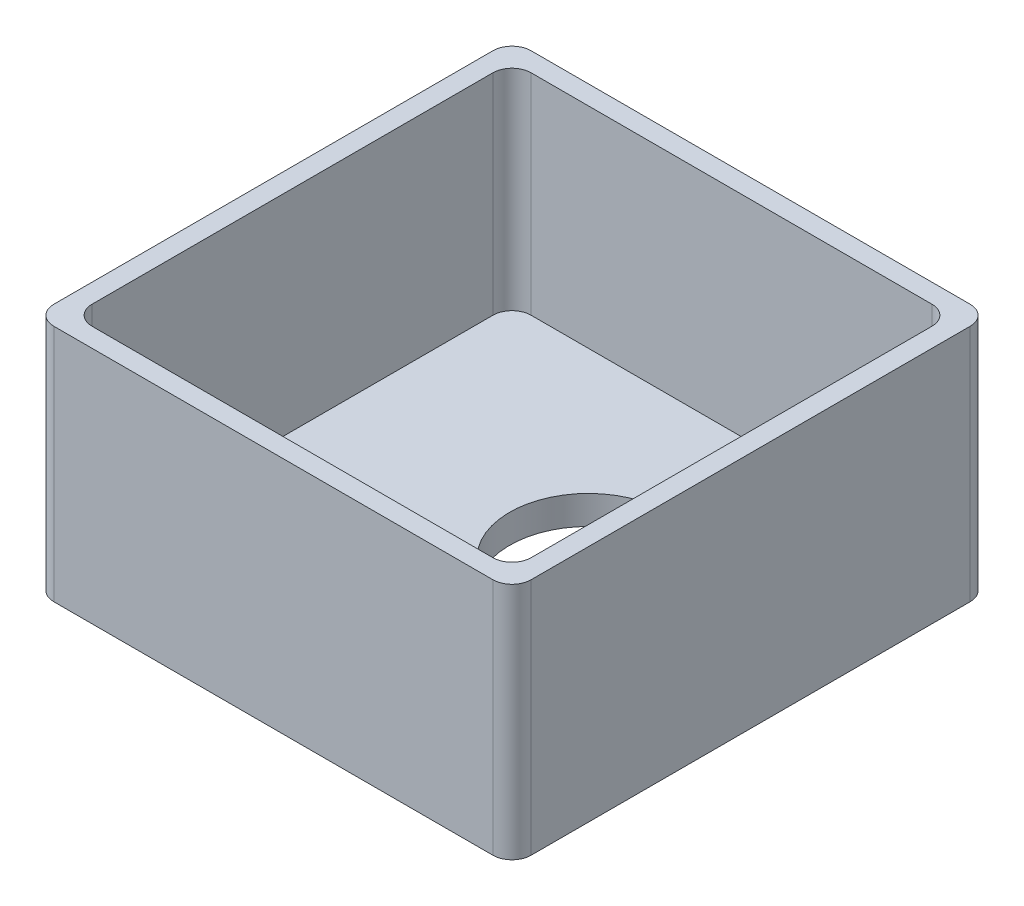
from build123d import *

# Parameters (mm, degrees)
SZKIC3_W                    = 50
SZKIC3_H                    = 50
SZKIC3_R                    = 18
SZKIC3_R_2                  = 8.25
DODANIE_WYCI_GNI_CIE2_DEPTH = 3
SZKIC4_W                    = 50
SZKIC4_H                    = 50
SZKIC4_W_2                  = 46
SZKIC4_H_2                  = 46
DODANIE_WYCI_GNI_CIE3_DEPTH = 22
ZAOKR_GLENIE1_R             = 2


with BuildPart() as part:
    # Szkic3 → Dodanie-wyciągnięcie2 (new body)
    with BuildSketch(Plane(origin=(0, 0, 0), x_dir=(1, 0, 0), z_dir=(0, 1, 0))):
        Rectangle(SZKIC3_W, SZKIC3_H)
        with Locations((4, 4)):
            Circle(SZKIC3_R, mode=Mode.SUBTRACT)
        with Locations((4, 4)):
            Circle(SZKIC3_R)
        with Locations((4, 4)):
            Circle(SZKIC3_R_2, mode=Mode.SUBTRACT)
    extrude(amount=DODANIE_WYCI_GNI_CIE2_DEPTH)

    # Szkic4 → Dodanie-wyciągnięcie3 (add)
    with BuildSketch(Plane(origin=(0, 3, 0), x_dir=(1, 0, 0), z_dir=(0, 1, 0))):
        Rectangle(SZKIC4_W, SZKIC4_H)
        Rectangle(SZKIC4_W_2, SZKIC4_H_2, mode=Mode.SUBTRACT)
    extrude(amount=DODANIE_WYCI_GNI_CIE3_DEPTH)

    # Zaokrąglenie1
    zaokr_glenie1_edges = [part.edges().sort_by_distance(p)[0] for p in [
        (-25, 12.5, 25),
        (-25, 12.5, -25),
        (25, 12.5, -25),
        (25, 12.5, 25),
        (23, 14, -23),
        (-23, 14, -23),
        (-23, 14, 23),
        (23, 14, 23),
    ]]
    fillet(zaokr_glenie1_edges, radius=ZAOKR_GLENIE1_R)


solid = part.part
